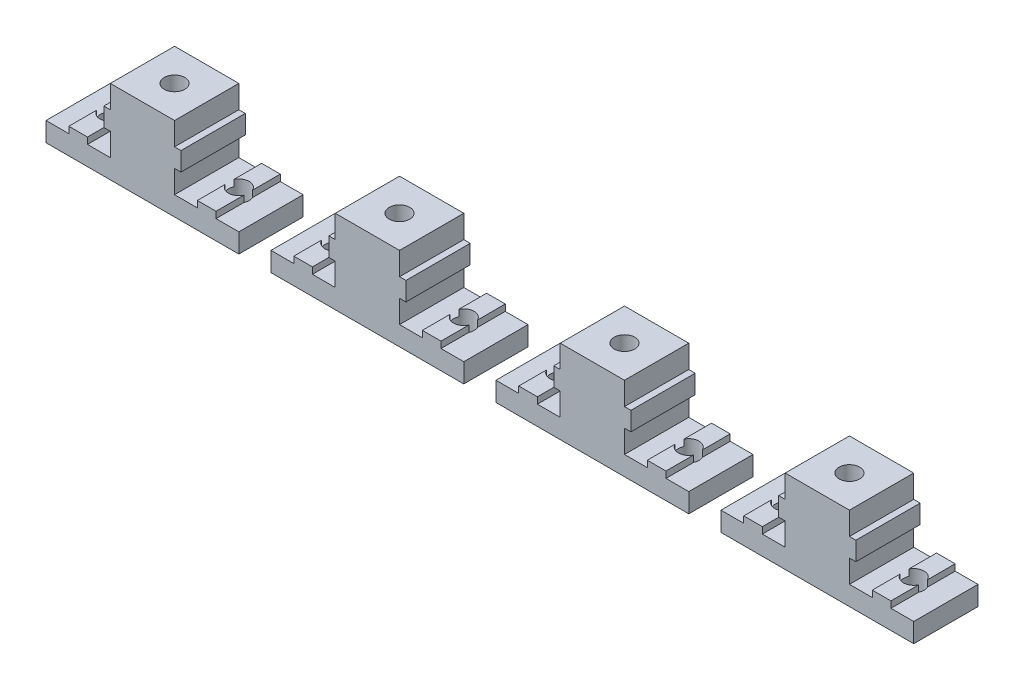
from build123d import *

# Parameters (mm, degrees)
MAIN_DEPTH                 = 10
ESQUISSE2_R                = 1.6
TOPHOLE_DEPTH              = 21.14944168
ESQUISSE3_R                = 1.6
ENL_V_MAT_EXTRU_2_DEPTH    = 23.226110771
R_P_TITION_LIN_AIRE3_COUNT = 4
R_P_TITION_LIN_AIRE3_PITCH = 35


with BuildPart() as part:
    # Esquisse1 → Main (new body)
    with BuildSketch(Plane.XY):
        Polygon((-15, 0), (-15, 3), (-11.45, 3), (-11.45, 4), (-8.55, 4), (-8.55, 3), (-5, 3), (-5, 6.55), (-6, 6.55), (-6, 9.45), (-5, 9.45), (-5, 13), (0, 13), (0, 0), align=None)
    main = extrude(amount=MAIN_DEPTH)

    # Esquisse2 → TopHole (cut, through all)
    with BuildSketch(Plane(origin=(0, 4, 0), x_dir=(1, 0, 0), z_dir=(0, 1, 0))):
        with Locations((-10, -5)):
            Circle(ESQUISSE2_R)
    tophole = extrude(amount=-TOPHOLE_DEPTH, mode=Mode.SUBTRACT)

    # Symétrie1: Main, TopHole across plane
    add(main.mirror(Plane(origin=(0, 0, 0), x_dir=(0, 0, 1), z_dir=(1, 0, 0))))
    add(tophole.mirror(Plane(origin=(0, 0, 0), x_dir=(0, 0, 1), z_dir=(1, 0, 0))), mode=Mode.SUBTRACT)

    # Esquisse3 → Enlèv. mat.-Extru.2 (cut, through all)
    with BuildSketch(Plane(origin=(0, 13, 0), x_dir=(1, 0, 0), z_dir=(0, 1, 0))):
        with Locations((0, -5)):
            Circle(ESQUISSE3_R)
    extrude(amount=-ENL_V_MAT_EXTRU_2_DEPTH, mode=Mode.SUBTRACT)


with BuildPart() as r_p_tition_lin_aire3_1:
    # Répétition linéaire3: pattern copy
    add(part.part.moved(Location(Vector(1, 0, 0) * (1 * R_P_TITION_LIN_AIRE3_PITCH))))


with BuildPart() as r_p_tition_lin_aire3_2:
    # Répétition linéaire3: pattern copy
    add(part.part.moved(Location(Vector(1, 0, 0) * (2 * R_P_TITION_LIN_AIRE3_PITCH))))


with BuildPart() as r_p_tition_lin_aire3_3:
    # Répétition linéaire3: pattern copy
    add(part.part.moved(Location(Vector(1, 0, 0) * (3 * R_P_TITION_LIN_AIRE3_PITCH))))


solid = Compound([part.part, r_p_tition_lin_aire3_1.part, r_p_tition_lin_aire3_2.part, r_p_tition_lin_aire3_3.part])
